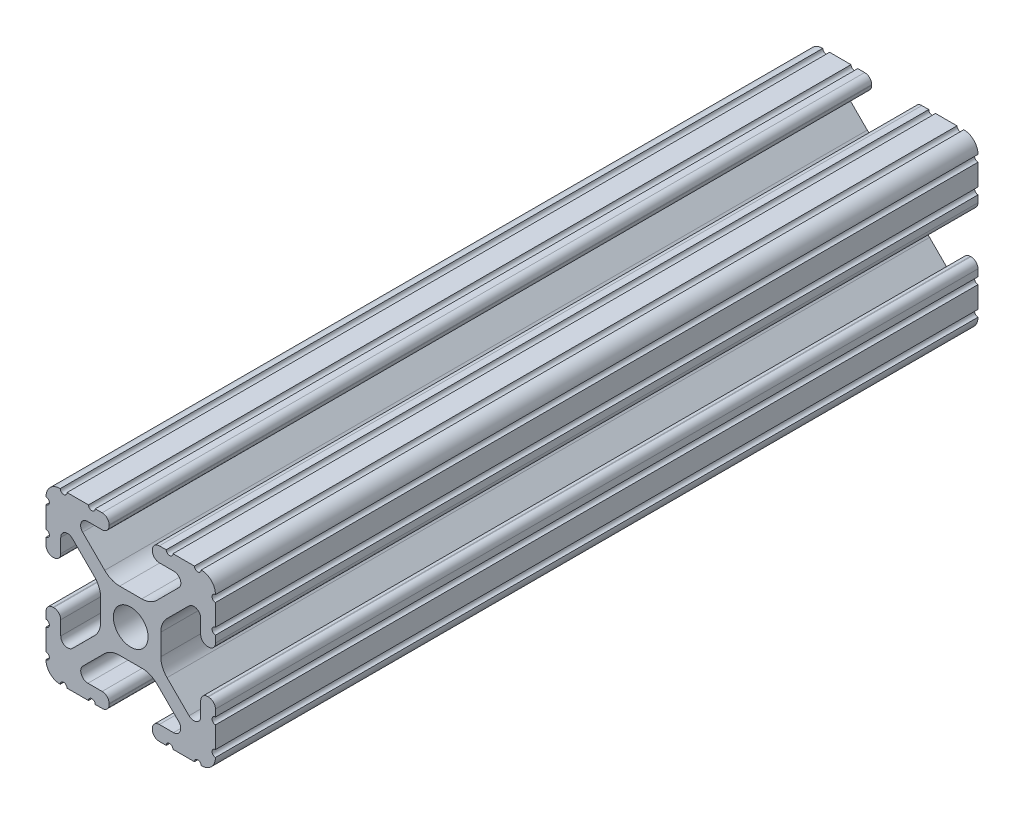
from build123d import *

# Parameters (mm, degrees)
SKETCH1_R           = 2.6035
BOSS_EXTRUDE1_DEPTH = 57.15


with BuildPart() as part:
    # Sketch1 → Boss-Extrude1 (new body, symmetric)
    with BuildSketch(Plane.XY):
        with BuildLine():
            Line((-7.179650497, -8.645192506), (-3.952270251, -5.423690499))
            ThreePointArc((-3.952270251, -5.423690499), (-2.922936451, -4.736929036), (-1.709253557, -4.4958))
            Line((-1.709253557, -4.4958), (1.709253557, -4.4958))
            ThreePointArc((1.709253557, -4.4958), (2.922936451, -4.736929036), (3.952270251, -5.423690499))
            Line((3.952270251, -5.423690499), (7.179650497, -8.645192506))
            ThreePointArc((7.179650497, -8.645192506), (7.41473083, -9.822813117), (6.416408329, -10.4902))
            Line((6.416408329, -10.4902), (4.287512407, -10.4902))
            ThreePointArc((4.287512407, -10.4902), (3.54574862, -10.79744862), (3.2385, -11.539212407))
            Line((3.2385, -11.539212407), (3.2385, -11.650987593))
            ThreePointArc((3.2385, -11.650987593), (3.54574862, -12.39275138), (4.287512407, -12.7))
            Line((4.287512407, -12.7), (5.317126718, -12.7))
            ThreePointArc((5.317126718, -12.7), (5.825126718, -12.192), (6.333126718, -12.7))
            Line((6.333126718, -12.7), (9.550443118, -12.7))
            ThreePointArc((9.550443118, -12.7), (10.058366869, -12.192000006), (10.566443095, -12.699847501))
            ThreePointArc((10.566443095, -12.699847501), (12.082537762, -12.08250727), (12.699846982, -10.566399977))
            ThreePointArc((12.699846982, -10.566399977), (12.192000006, -10.058323491), (12.7, -9.5504))
            Line((12.7, -9.5504), (12.7, -6.3330836))
            ThreePointArc((12.7, -6.3330836), (12.192, -5.8250836), (12.7, -5.3170836))
            Line((12.7, -5.3170836), (12.7, -4.287469289))
            ThreePointArc((12.7, -4.287469289), (12.39275138, -3.545705502), (11.650987593, -3.238456882))
            Line((11.650987593, -3.238456882), (11.539212407, -3.238456882))
            ThreePointArc((11.539212407, -3.238456882), (10.79744862, -3.545705502), (10.4902, -4.287469289))
            Line((10.4902, -4.287469289), (10.4902, -6.402089023))
            ThreePointArc((10.4902, -6.402089023), (9.856505071, -7.351067942), (8.737131347, -7.129408934))
            Line((8.737131347, -7.129408934), (5.441005833, -3.840816462))
            ThreePointArc((5.441005833, -3.840816462), (4.750877967, -2.809883091), (4.5085, -1.593185507))
            Line((4.5085, -1.593185507), (4.5085, 1.593185507))
            ThreePointArc((4.5085, 1.593185507), (4.750877967, 2.809883091), (5.441005833, 3.840816462))
            Line((5.441005833, 3.840816462), (8.737131347, 7.129408934))
            ThreePointArc((8.737131347, 7.129408934), (9.856505071, 7.351067942), (10.4902, 6.402089023))
            Line((10.4902, 6.402089023), (10.4902, 4.287469289))
            ThreePointArc((10.4902, 4.287469289), (10.79744862, 3.545705502), (11.539212407, 3.238456882))
            Line((11.539212407, 3.238456882), (11.650987593, 3.238456882))
            ThreePointArc((11.650987593, 3.238456882), (12.39275138, 3.545705502), (12.7, 4.287469289))
            Line((12.7, 4.287469289), (12.7, 5.3170836))
            ThreePointArc((12.7, 5.3170836), (12.192, 5.8250836), (12.7, 6.3330836))
            Line((12.7, 6.3330836), (12.7, 9.5504))
            ThreePointArc((12.7, 9.5504), (12.192000006, 10.058323491), (12.699846982, 10.566399977))
            ThreePointArc((12.699846982, 10.566399977), (12.082537762, 12.08250727), (10.566443095, 12.699847501))
            ThreePointArc((10.566443095, 12.699847501), (10.058366869, 12.192000006), (9.550443118, 12.7))
            Line((9.550443118, 12.7), (6.333126718, 12.7))
            ThreePointArc((6.333126718, 12.7), (5.825126718, 12.192), (5.317126718, 12.7))
            Line((5.317126718, 12.7), (4.287512407, 12.7))
            ThreePointArc((4.287512407, 12.7), (3.54574862, 12.39275138), (3.2385, 11.650987593))
            Line((3.2385, 11.650987593), (3.2385, 11.539212407))
            ThreePointArc((3.2385, 11.539212407), (3.54574862, 10.79744862), (4.287512407, 10.4902))
            Line((4.287512407, 10.4902), (6.476788598, 10.4902))
            ThreePointArc((6.476788598, 10.4902), (7.432222385, 9.85140422), (7.207036008, 8.724370562))
            Line((7.207036008, 8.724370562), (3.898272566, 5.423169045))
            ThreePointArc((3.898272566, 5.423169045), (2.869120213, 4.736787962), (1.655778399, 4.4958))
            Line((1.655778399, 4.4958), (-1.655778399, 4.4958))
            ThreePointArc((-1.655778399, 4.4958), (-2.869120213, 4.736787962), (-3.898272566, 5.423169045))
            Line((-3.898272566, 5.423169045), (-7.207036008, 8.724370562))
            ThreePointArc((-7.207036008, 8.724370562), (-7.432222385, 9.85140422), (-6.476788598, 10.4902))
            Line((-6.476788598, 10.4902), (-4.287512407, 10.4902))
            ThreePointArc((-4.287512407, 10.4902), (-3.54574862, 10.79744862), (-3.2385, 11.539212407))
            Line((-3.2385, 11.539212407), (-3.2385, 11.650987593))
            ThreePointArc((-3.2385, 11.650987593), (-3.54574862, 12.39275138), (-4.287512407, 12.7))
            Line((-4.287512407, 12.7), (-5.317126718, 12.7))
            ThreePointArc((-5.317126718, 12.7), (-5.825126718, 12.192), (-6.333126718, 12.7))
            Line((-6.333126718, 12.7), (-9.550443118, 12.7))
            ThreePointArc((-9.550443118, 12.7), (-10.058366869, 12.192000006), (-10.566443095, 12.699847501))
            ThreePointArc((-10.566443095, 12.699847501), (-12.082537762, 12.08250727), (-12.699846982, 10.566399977))
            ThreePointArc((-12.699846982, 10.566399977), (-12.192000006, 10.058323491), (-12.7, 9.5504))
            Line((-12.7, 9.5504), (-12.7, 6.3330836))
            ThreePointArc((-12.7, 6.3330836), (-12.192, 5.8250836), (-12.7, 5.3170836))
            Line((-12.7, 5.3170836), (-12.7, 4.287469289))
            ThreePointArc((-12.7, 4.287469289), (-12.39275138, 3.545705502), (-11.650987593, 3.238456882))
            Line((-11.650987593, 3.238456882), (-11.539212407, 3.238456882))
            ThreePointArc((-11.539212407, 3.238456882), (-10.79744862, 3.545705502), (-10.4902, 4.287469289))
            Line((-10.4902, 4.287469289), (-10.4902, 6.402089023))
            ThreePointArc((-10.4902, 6.402089023), (-9.856505071, 7.351067942), (-8.737131347, 7.129408934))
            Line((-8.737131347, 7.129408934), (-5.441005833, 3.840816462))
            ThreePointArc((-5.441005833, 3.840816462), (-4.750877967, 2.809883091), (-4.5085, 1.593185507))
            Line((-4.5085, 1.593185507), (-4.5085, -1.593185507))
            ThreePointArc((-4.5085, -1.593185507), (-4.750877967, -2.809883091), (-5.441005833, -3.840816462))
            Line((-5.441005833, -3.840816462), (-8.737131347, -7.129408934))
            ThreePointArc((-8.737131347, -7.129408934), (-9.856505071, -7.351067942), (-10.4902, -6.402089023))
            Line((-10.4902, -6.402089023), (-10.4902, -4.287469289))
            ThreePointArc((-10.4902, -4.287469289), (-10.79744862, -3.545705502), (-11.539212407, -3.238456882))
            Line((-11.539212407, -3.238456882), (-11.650987593, -3.238456882))
            ThreePointArc((-11.650987593, -3.238456882), (-12.39275138, -3.545705502), (-12.7, -4.287469289))
            Line((-12.7, -4.287469289), (-12.7, -5.3170836))
            ThreePointArc((-12.7, -5.3170836), (-12.192, -5.8250836), (-12.7, -6.3330836))
            Line((-12.7, -6.3330836), (-12.7, -9.5504))
            ThreePointArc((-12.7, -9.5504), (-12.192000006, -10.058323491), (-12.699846982, -10.566399977))
            ThreePointArc((-12.699846982, -10.566399977), (-12.082537762, -12.08250727), (-10.566443095, -12.699847501))
            ThreePointArc((-10.566443095, -12.699847501), (-10.058366869, -12.192000006), (-9.550443118, -12.7))
            Line((-9.550443118, -12.7), (-6.333126718, -12.7))
            ThreePointArc((-6.333126718, -12.7), (-5.825126718, -12.192), (-5.317126718, -12.7))
            Line((-5.317126718, -12.7), (-4.287512407, -12.7))
            ThreePointArc((-4.287512407, -12.7), (-3.54574862, -12.39275138), (-3.2385, -11.650987593))
            Line((-3.2385, -11.650987593), (-3.2385, -11.539212407))
            ThreePointArc((-3.2385, -11.539212407), (-3.54574862, -10.79744862), (-4.287512407, -10.4902))
            Line((-4.287512407, -10.4902), (-6.416408329, -10.4902))
            ThreePointArc((-6.416408329, -10.4902), (-7.41473083, -9.822813117), (-7.179650497, -8.645192506))
        make_face()
        Circle(SKETCH1_R, mode=Mode.SUBTRACT)
    extrude(amount=BOSS_EXTRUDE1_DEPTH, both=True)


solid = part.part
